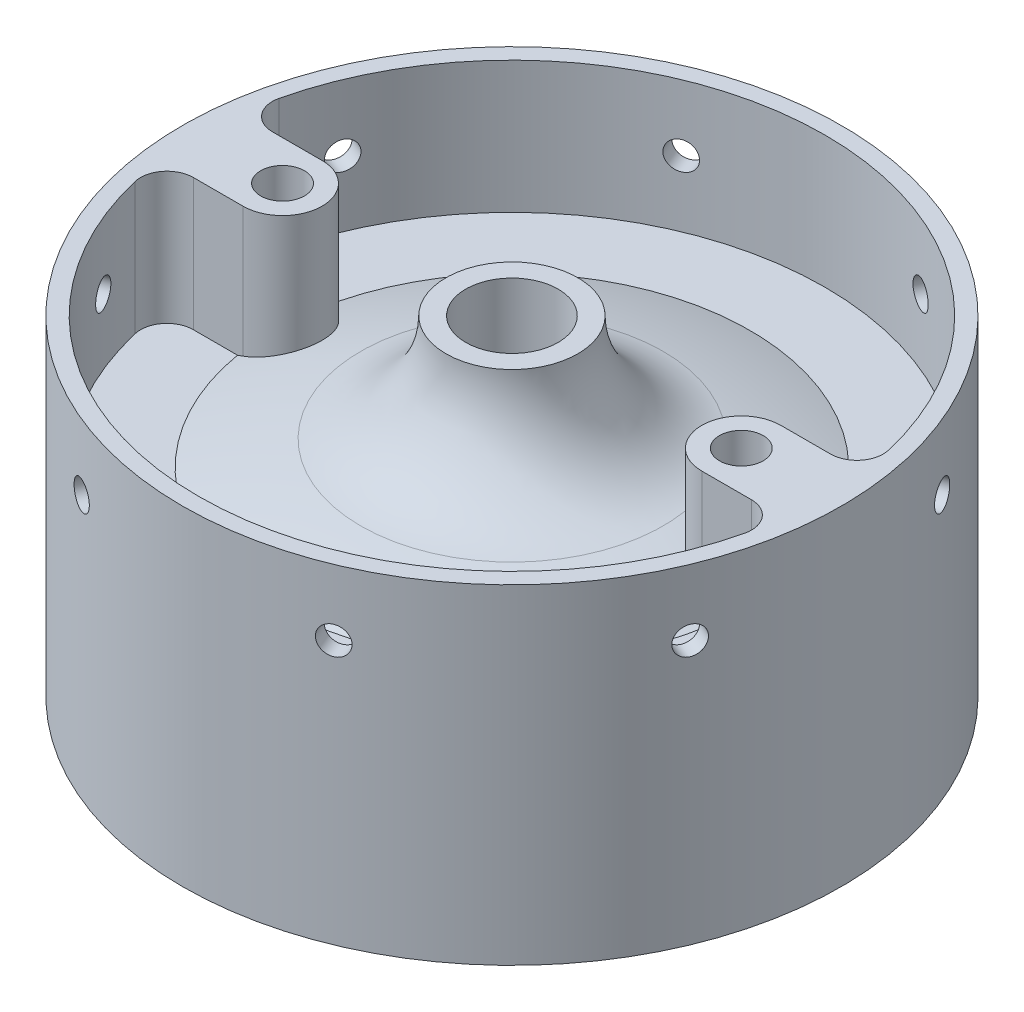
from build123d import *

# Parameters (mm, degrees)
CIRPATTERN1_COUNT    = 8
SKETCH10_W           = 4.2164
SKETCH10_H           = 38.1
BOSS_EXTRUDE1_DEPTH  = 25.4
FILLET1_R            = 5.08
SKETCH13_W           = 4.2164
SKETCH13_H           = 25.401
FILLET1_OF_MIRROR1_R = 5.08


with BuildPart() as part:
    # Sketch1 → Revolve2 (revolve)
    with BuildSketch(Plane.XY, mode=Mode.PRIVATE) as revolve2_sk:
        with BuildLine():
            Line((-63.5, 0), (-63.5, 63.5))
            Line((-63.5, 63.5), (-60.325, 63.5))
            Line((-60.325, 63.5), (-60.325, 38.1))
            Line((-60.325, 38.1), (-45.887987012, 38.1))
            ThreePointArc((-45.887987012, 38.1), (-37.592867218, 40.821117068), (-29.138150343, 42.996261447))
            ThreePointArc((-29.138150343, 42.996261447), (-17.316898362, 50.360212318), (-12.7, 63.5))
            Line((-12.7, 63.5), (-8.90651, 63.5))
            Line((-8.90651, 63.5), (-8.90651, 48.26))
            ThreePointArc((-8.90651, 48.26), (-11.993485386, 40.807382156), (-19.446103231, 37.720406769))
            ThreePointArc((-19.446103231, 37.720406769), (-32.858422717, 34.893706556), (-45.887987012, 30.638004221))
            ThreePointArc((-45.887987012, 30.638004221), (-54.721458819, 23.640172111), (-58.05478896, 12.875006597))
            Line((-58.05478896, 12.875006597), (-60.325, 0))
            Line((-60.325, 0), (-63.5, 0))
        make_face()
    revolve(revolve2_sk.sketch.rotate(Axis((0, 127.060987048, 0), (0, -1, 0)), 270), axis=Axis((0, 127.060987048, 0), (0, -1, 0)))

    # Sketch5 → 3 _0.213_ Diameter Hole1 (revolve, cut)
    with BuildSketch(Plane(origin=(-24.300397955, 50.8, 58.666350314), x_dir=(0.9238795325112865, 0, 0.3826834323650904), z_dir=(0, 1, 0))):
        Polygon((0, 0), (0, 13.309388061), (2.7051, 11.684), (2.7051, 0), align=None)
    f_3_0_213_diameter_hole1 = revolve(axis=Axis((-26.730437751, 50.8, 64.532985346), (0.3826834323650904, 0, -0.9238795325112865)), mode=Mode.SUBTRACT)

    # CirPattern1: 3 _0.213_ Diameter Hole1 ×8 about axis
    cirpattern1_axis = Axis((0, 127.060987048, 0), (0, -1, 0))
    for i in range(1, CIRPATTERN1_COUNT):
        add(f_3_0_213_diameter_hole1.rotate(cirpattern1_axis, i * 360 / CIRPATTERN1_COUNT), mode=Mode.SUBTRACT)

    # Sketch10 → Q _0.332_ Diameter Hole2 (revolve, cut)
    with BuildSketch(Plane(origin=(-44.196, 38.1, 0), x_dir=(0, 0, 1), z_dir=(1, 0, 0))):
        with Locations((2.1082, 19.05)):
            Rectangle(SKETCH10_W, SKETCH10_H)
    revolve(axis=Axis((-44.196, 44.45, 0), (0, -1, 0)), mode=Mode.SUBTRACT)

    # Sketch11 → Boss-Extrude1 (add)
    with BuildSketch(Plane(origin=(0, 38.1, 0), x_dir=(1, 0, 0), z_dir=(0, 1, 0))):
        with BuildLine():
            Line((-59.841801652, 7.62), (-44.196, 7.62))
            ThreePointArc((-44.196, 7.62), (-36.576, -3.3653e-05), (-44.196067307, -7.62))
            Line((-44.196067307, -7.62), (-59.84181925, -7.619861803))
            ThreePointArc((-59.84181925, -7.619861803), (-60.325, 6.9657e-05), (-59.841801652, 7.62))
        make_face()
    boss_extrude1 = extrude(amount=BOSS_EXTRUDE1_DEPTH)

    # Fillet1
    fillet1_edges = [part.edges().sort_by_distance(p)[0] for p in [
        (-59.84181925, 50.8, 7.619861803),
        (-59.841801652, 50.8, -7.62),
    ]]
    fillet(fillet1_edges, radius=FILLET1_R)

    # Sketch13 → Q _0.332_ Diameter Hole3 (revolve, cut)
    with BuildSketch(Plane(origin=(-44.196, 38.1, 0), x_dir=(0, 0, -1), z_dir=(1, 0, 0))):
        with Locations((2.1082, 12.7005)):
            Rectangle(SKETCH13_W, SKETCH13_H)
    q_0_332_diameter_hole3 = revolve(axis=Axis((-44.196, 31.75, 0), (0, 1, 0)), mode=Mode.SUBTRACT)

    # Mirror1: Boss-Extrude1, Q _0.332_ Diameter Hole3 across plane
    add(boss_extrude1.mirror(Plane(origin=(0, 0, 0), x_dir=(0, 0, 1), z_dir=(1, 0, 0))))
    add(q_0_332_diameter_hole3.mirror(Plane(origin=(0, 0, 0), x_dir=(0, 0, 1), z_dir=(1, 0, 0))), mode=Mode.SUBTRACT)

    # Fillet1 of Mirror1
    fillet1_of_mirror1_edges = [part.edges().sort_by_distance(p)[0] for p in [
        (59.84181925, 50.8, 7.619861803),
        (59.841801652, 50.8, -7.62),
    ]]
    fillet(fillet1_of_mirror1_edges, radius=FILLET1_OF_MIRROR1_R)


solid = part.part
